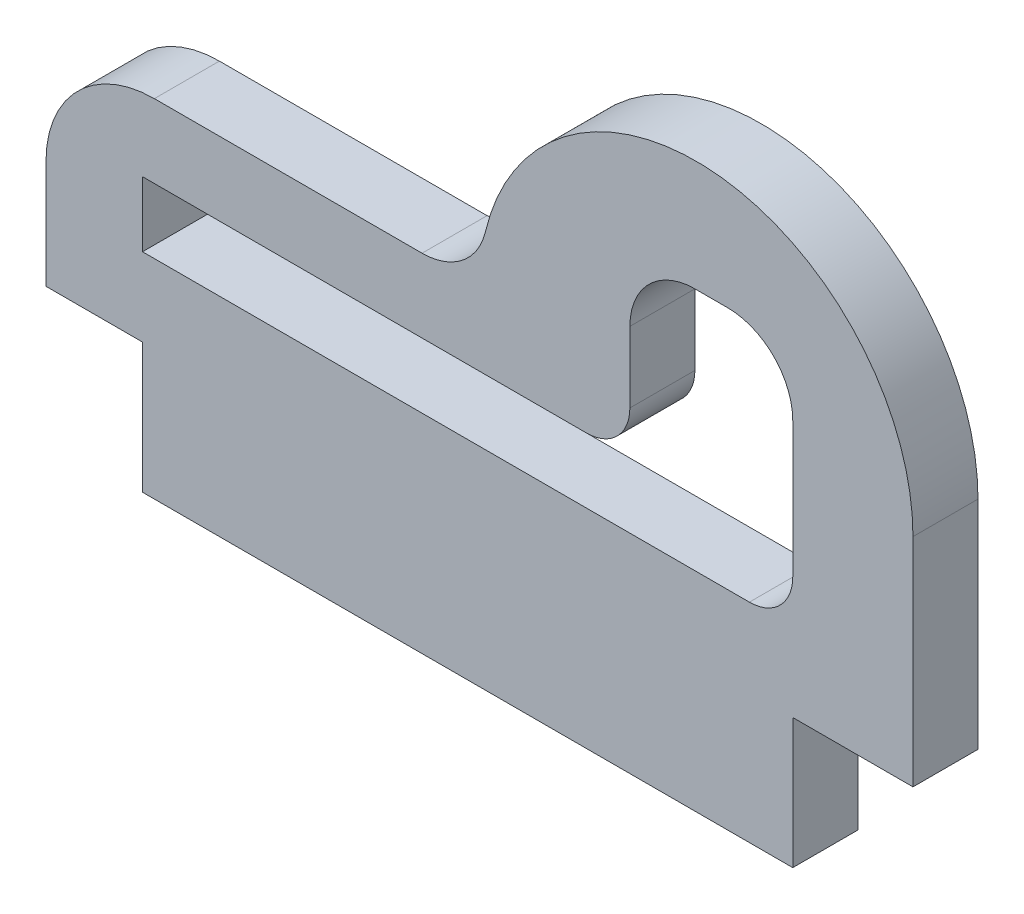
from build123d import *

# Parameters (mm, degrees)
SALIENTE_EXTRUIR1_DEPTH = 3


with BuildPart() as part:
    # Croquis1 → Saliente-Extruir1 (new body)
    with BuildSketch(Plane.XY):
        with BuildLine():
            Line((-2.649110641, 0), (-15, 0))
            ThreePointArc((-15, 0), (-18.535533906, -1.464466094), (-20, -5))
            Line((-20, -5), (-20, -10))
            Line((-20, -10), (-15.546822742, -10))
            Line((-15.546822742, -10), (-15.546822742, -16))
            Line((-15.546822742, -16), (14.453177258, -16))
            Line((14.453177258, -16), (14.453177258, -10))
            Line((14.453177258, -10), (20, -10))
            Line((20, -10), (20, 0))
            ThreePointArc((20, 0), (11.161711866, 9.932292059), (0.269914892, 2.307692308))
            ThreePointArc((0.269914892, 2.307692308), (-0.788589622, 0.646606378), (-2.649110641, 0))
        make_face()
        with BuildLine():
            Line((-15.546822742, -6.391304348), (12.453177258, -6.391304348))
            ThreePointArc((12.453177258, -6.391304348), (13.86739082, -5.80551791), (14.453177258, -4.391304348))
            Line((14.453177258, -4.391304348), (14.453177258, -3.391304348))
            Line((14.453177258, -3.391304348), (14.453177258, 1.869565217))
            ThreePointArc((14.453177258, 1.869565217), (13.574497601, 3.990885561), (11.453177258, 4.869565217))
            Line((11.453177258, 4.869565217), (9.93812709, 4.869565217))
            ThreePointArc((9.93812709, 4.869565217), (7.816806747, 3.990885561), (6.93812709, 1.869565217))
            Line((6.93812709, 1.869565217), (6.93812709, -1.391304348))
            ThreePointArc((6.93812709, -1.391304348), (6.352340653, -2.80551791), (4.93812709, -3.391304348))
            Line((4.93812709, -3.391304348), (-15.546822742, -3.391304348))
            Line((-15.546822742, -3.391304348), (-15.546822742, -6.391304348))
        make_face(mode=Mode.SUBTRACT)
    extrude(amount=SALIENTE_EXTRUIR1_DEPTH)


solid = part.part
